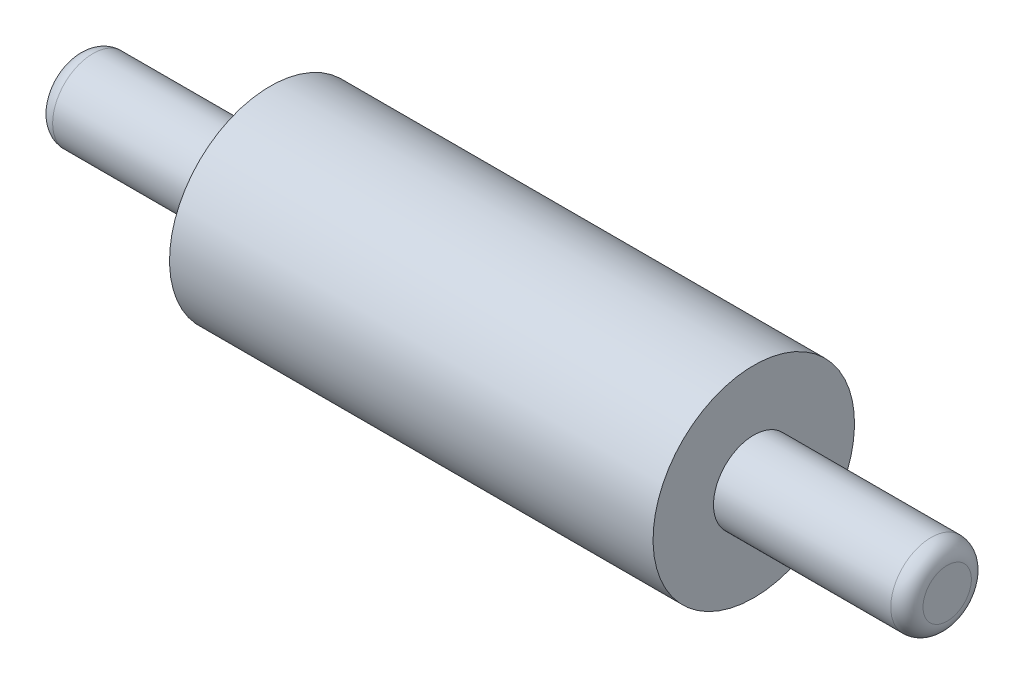
from build123d import *

# Parameters (mm, degrees)
FILLET1_R = 2.54


with BuildPart() as part:
    # Sketch1 → Revolve2 (revolve)
    with BuildSketch(Plane.XY):
        Polygon((-68.58, 0), (68.58, 0), (68.58, 6.35), (38.1, 6.35), (38.1, 15.875), (-38.1, 15.875), (-38.1, 6.35), (-68.58, 6.35), align=None)
    revolve(axis=Axis((-68.58, 0, 0), (1, 0, 0)))

    # Fillet1
    fillet1_edges = [part.edges().sort_by_distance(p)[0] for p in [
        (-68.58, -6.35, 0),
        (68.58, -6.35, 0),
    ]]
    fillet(fillet1_edges, radius=FILLET1_R)


solid = part.part
